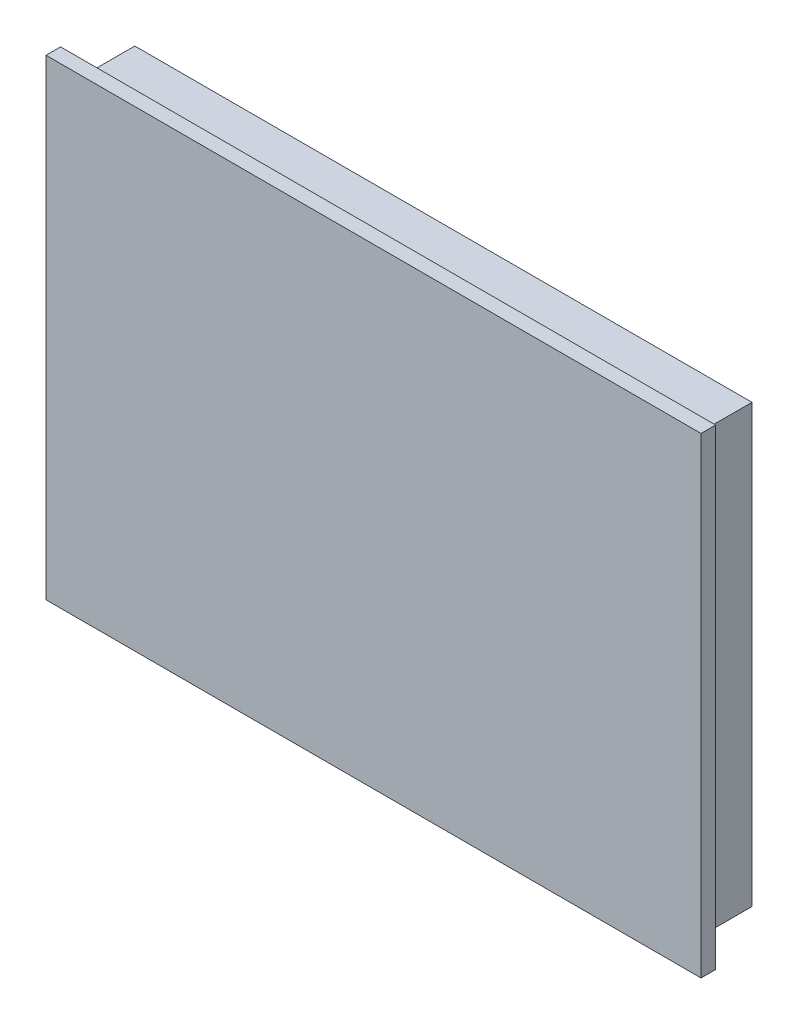
from build123d import *

# Parameters (mm, degrees)
SKETCH_1_W          = 225
SKETCH_1_H          = 162
EXTRUDE_1_DEPTH     = 5
SKETCH_3_W          = 212
SKETCH_3_H          = 150
EXTRUDE_2_DEPTH     = 19
EXTRUDE_3_DEPTH     = 10
SKETCH_5_W          = 20
SKETCH_5_H          = 65.649810637
SKETCH_5_H_2        = 64
CUT_EXTRUDE_1_DEPTH = 10
SKETCH_7_R          = 2
SKETCH_7_W          = 8
SKETCH_7_H          = 12
SKETCH_7_R_2        = 0.262594618
SKETCH_7_R_3        = 0.290999542
EXTRUDE_4_DEPTH     = 5


with BuildPart() as part:
    # 草图1 → 凸台-拉伸1 (new body)
    with BuildSketch(Plane.XY):
        with Locations((112.5, 81)):
            Rectangle(SKETCH_1_W, SKETCH_1_H)
    extrude(amount=EXTRUDE_1_DEPTH)

    # 草图3 → 凸台-拉伸2 (add)
    with BuildSketch(Plane(origin=(0, 0, 0), x_dir=(-1, 0, 0), z_dir=(0, 0, -1))):
        with Locations((-112.5, 81)):
            Rectangle(SKETCH_3_W, SKETCH_3_H)
    extrude(amount=EXTRUDE_2_DEPTH)

    # 草图4 → 凸台-拉伸3 (add)
    with BuildSketch(Plane(origin=(0, 0, -19), x_dir=(-1, 0, 0), z_dir=(0, 0, -1))):
        Polygon((-112.5, 136), (-188, 136), (-188, 26), (-37, 26), (-37, 136), align=None)
    extrude(amount=EXTRUDE_3_DEPTH)

    # 草图5 → 切除-拉伸1 (cut)
    with BuildSketch(Plane(origin=(0, 0, -29), x_dir=(-1, 0, 0), z_dir=(0, 0, -1))):
        with Locations((-178, 88.175094682)):
            Rectangle(SKETCH_5_W, SKETCH_5_H)
        with Locations((-47, 89)):
            Rectangle(SKETCH_5_W, SKETCH_5_H_2)
    extrude(amount=-CUT_EXTRUDE_1_DEPTH, mode=Mode.SUBTRACT)

    # 草图7 → 凸台-拉伸4 (add)
    with BuildSketch(Plane(origin=(0, 0, -19), x_dir=(-1, 0, 0), z_dir=(0, 0, -1))):
        with Locations((-50, 65.359909726)):
            Circle(SKETCH_7_R)
        with Locations((-50, 91.297088519)):
            Circle(SKETCH_7_R)
        with Locations((-50, 111.883776524)):
            Rectangle(SKETCH_7_W, SKETCH_7_H)
        with Locations((-50, 115.545534251)):
            Circle(SKETCH_7_R_2, mode=Mode.SUBTRACT)
        with Locations((-50, 108.299645663)):
            Circle(SKETCH_7_R_3, mode=Mode.SUBTRACT)
        with BuildLine():
            Line((-54, 84.588527339), (-54, 72.068223644))
            ThreePointArc((-54, 72.068223644), (-52.877182181, 69.728098207), (-50.349208627, 69.139662463))
            Line((-50.349208627, 69.139662463), (-47.349208627, 69.80632913))
            ThreePointArc((-47.349208627, 69.80632913), (-45.659874563, 70.85770813), (-45, 72.73489031))
            Line((-45, 72.73489031), (-45, 83.921860672))
            ThreePointArc((-45, 83.921860672), (-45.659874563, 85.799042853), (-47.349208627, 86.850421853))
            Line((-47.349208627, 86.850421853), (-50.349208627, 87.517088519))
            ThreePointArc((-50.349208627, 87.517088519), (-52.877182181, 86.928652776), (-54, 84.588527339))
        make_face()
    extrude(amount=EXTRUDE_4_DEPTH)


solid = part.part
